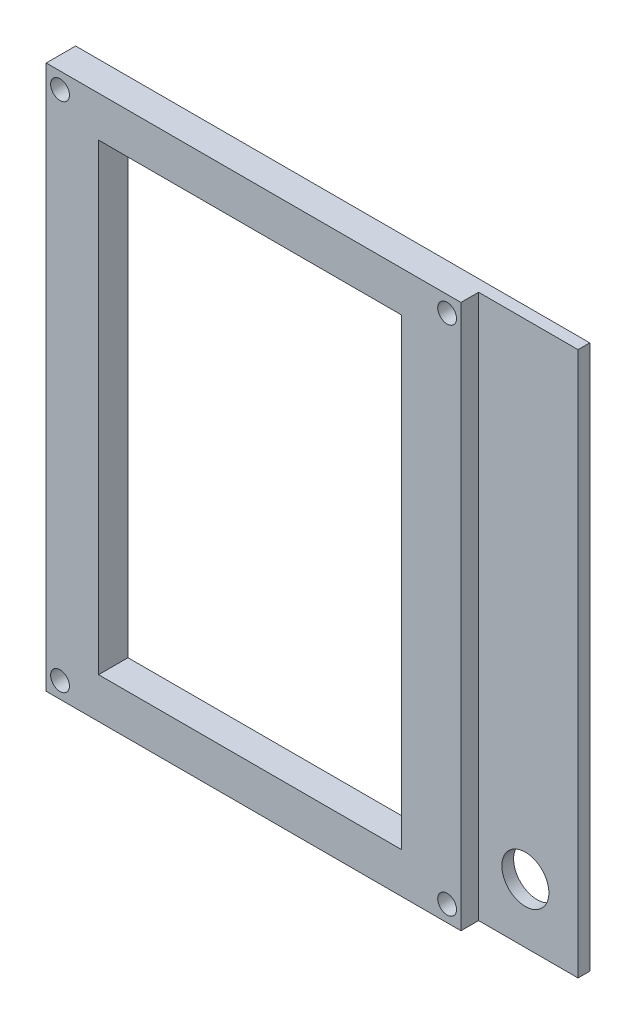
from build123d import *

# Parameters (mm, degrees)
SKETCH_1_W          = 71
SKETCH_1_H          = 93
SKETCH_1_R          = 1.6
SKETCH_1_W_2        = 51
SKETCH_1_H_2        = 78.2
EXTRUDE_1_DEPTH     = 5
SKETCH_2_W          = 71
SKETCH_2_H          = 93
SKETCH_2_W_2        = 70.5
SKETCH_2_H_2        = 92.5
CUT_EXTRUDE_1_DEPTH = 6
SKETCH_3_W          = 51.5
SKETCH_3_H          = 78.7
SKETCH_3_W_2        = 51
SKETCH_3_H_2        = 78.2
CUT_EXTRUDE_2_DEPTH = 6
SKETCH_5_W          = 27
SKETCH_5_H          = 92.5
SKETCH_5_R          = 1.6
EXTRUDE_3_DEPTH     = 2
SKETCH_7_R          = 4
CUT_EXTRUDE_3_DEPTH = 6


with BuildPart() as part:
    # Эскиз1 → Бобышка-Вытянуть1 (new body)
    with BuildSketch(Plane(origin=(0, 0, 92.662297423), x_dir=(-1, 0, 0), z_dir=(0, 0, -1))):
        with Locations((-39.5, 51)):
            Rectangle(SKETCH_1_W, SKETCH_1_H)
        with Locations((-6.6, 7.5)):
            Circle(SKETCH_1_R, mode=Mode.SUBTRACT)
        with Locations((-72.4, 7.5)):
            Circle(SKETCH_1_R, mode=Mode.SUBTRACT)
        with Locations((-6.6, 94.5)):
            Circle(SKETCH_1_R, mode=Mode.SUBTRACT)
        with Locations((-72.4, 94.5)):
            Circle(SKETCH_1_R, mode=Mode.SUBTRACT)
        with Locations((-38.9, 51)):
            Rectangle(SKETCH_1_W_2, SKETCH_1_H_2, mode=Mode.SUBTRACT)
    extrude(amount=EXTRUDE_1_DEPTH)

    # Эскиз2 → Вырез-Вытянуть1 (cut, through all)
    with BuildSketch(Plane.XY.offset(92.662297423)):
        with Locations((39.5, 51)):
            Rectangle(SKETCH_2_W, SKETCH_2_H)
        with Locations((39.5, 51)):
            Rectangle(SKETCH_2_W_2, SKETCH_2_H_2, mode=Mode.SUBTRACT)
    extrude(amount=-CUT_EXTRUDE_1_DEPTH, mode=Mode.SUBTRACT)

    # Эскиз3 → Вырез-Вытянуть2 (cut, through all)
    with BuildSketch(Plane.XY.offset(92.662297423)):
        with Locations((38.9, 51)):
            Rectangle(SKETCH_3_W, SKETCH_3_H)
        with Locations((38.9, 51)):
            Rectangle(SKETCH_3_W_2, SKETCH_3_H_2, mode=Mode.SUBTRACT)
    extrude(amount=-CUT_EXTRUDE_2_DEPTH, mode=Mode.SUBTRACT)

    # Эскиз5 → Бобышка-Вытянуть3 (add)
    with BuildSketch(Plane(origin=(0, 0, 87.662297423), x_dir=(-1, 0, 0), z_dir=(0, 0, -1))):
        with Locations((-78.15, 51)):
            Rectangle(SKETCH_5_W, SKETCH_5_H)
        with Locations((-72.4, 94.5)):
            Circle(SKETCH_5_R, mode=Mode.SUBTRACT)
        with Locations((-72.4, 7.5)):
            Circle(SKETCH_5_R, mode=Mode.SUBTRACT)
    extrude(amount=-EXTRUDE_3_DEPTH)

    # Эскиз7 → Вырез-Вытянуть3 (cut, through all)
    with BuildSketch(Plane(origin=(0, 0, 87.662297423), x_dir=(-1, 0, 0), z_dir=(0, 0, -1))):
        with Locations((-82.7, 14.8)):
            Circle(SKETCH_7_R)
    extrude(amount=-CUT_EXTRUDE_3_DEPTH, mode=Mode.SUBTRACT)


solid = part.part
